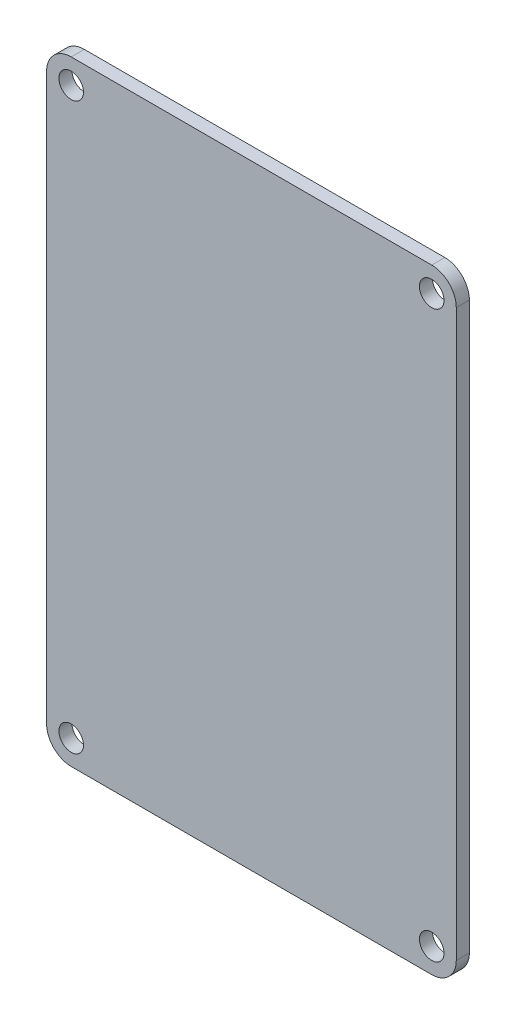
from build123d import *

# Parameters (mm, degrees)
BOSS_EXTRUDE1_DEPTH = 1.6
SKETCH2_R           = 1.5
CUT_EXTRUDE1_DEPTH  = 2.6


with BuildPart() as part:
    # Sketch1 → Boss-Extrude1 (new body)
    with BuildSketch(Plane.XY):
        with BuildLine():
            Line((-22, -37.5), (22, -37.5))
            ThreePointArc((22, -37.5), (24.121320344, -36.621320344), (25, -34.5))
            Line((25, -34.5), (25, 34.5))
            ThreePointArc((25, 34.5), (24.121320344, 36.621320344), (22, 37.5))
            Line((22, 37.5), (-22, 37.5))
            ThreePointArc((-22, 37.5), (-24.121320344, 36.621320344), (-25, 34.5))
            Line((-25, 34.5), (-25, -34.5))
            ThreePointArc((-25, -34.5), (-24.121320344, -36.621320344), (-22, -37.5))
        make_face()
    extrude(amount=BOSS_EXTRUDE1_DEPTH)

    # Sketch2 → Cut-Extrude1 (cut, through all)
    with BuildSketch(Plane(origin=(0, 0, 0), x_dir=(-1, 0, 0), z_dir=(0, 0, -1))):
        with Locations((-22, 34.5)):
            Circle(SKETCH2_R)
        with Locations((22, 34.5)):
            Circle(SKETCH2_R)
        with Locations((22, -34.5)):
            Circle(SKETCH2_R)
        with Locations((-22, -34.5)):
            Circle(SKETCH2_R)
    extrude(amount=-CUT_EXTRUDE1_DEPTH, mode=Mode.SUBTRACT)


solid = part.part
